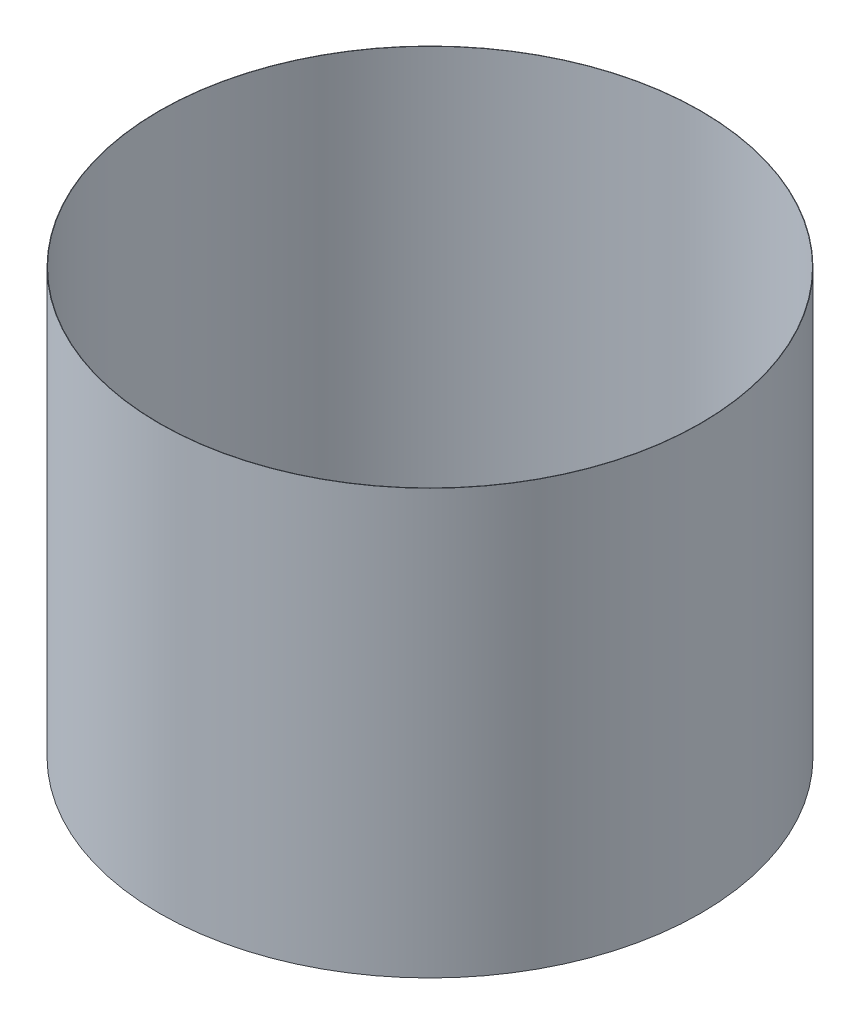
from build123d import *

# Parameters (mm, degrees)
SKETCH_1_R      = 255.42184874
SKETCH_1_R_2    = 255.12184874
EXTRUDE_1_DEPTH = 400


with BuildPart() as part:
    # 草图1 → 凸台-拉伸1 (new body)
    with BuildSketch(Plane(origin=(0, 0, 0), x_dir=(1, 0, 0), z_dir=(0, 1, 0))):
        Circle(SKETCH_1_R)
        Circle(SKETCH_1_R_2, mode=Mode.SUBTRACT)
    extrude(amount=EXTRUDE_1_DEPTH)


solid = part.part
